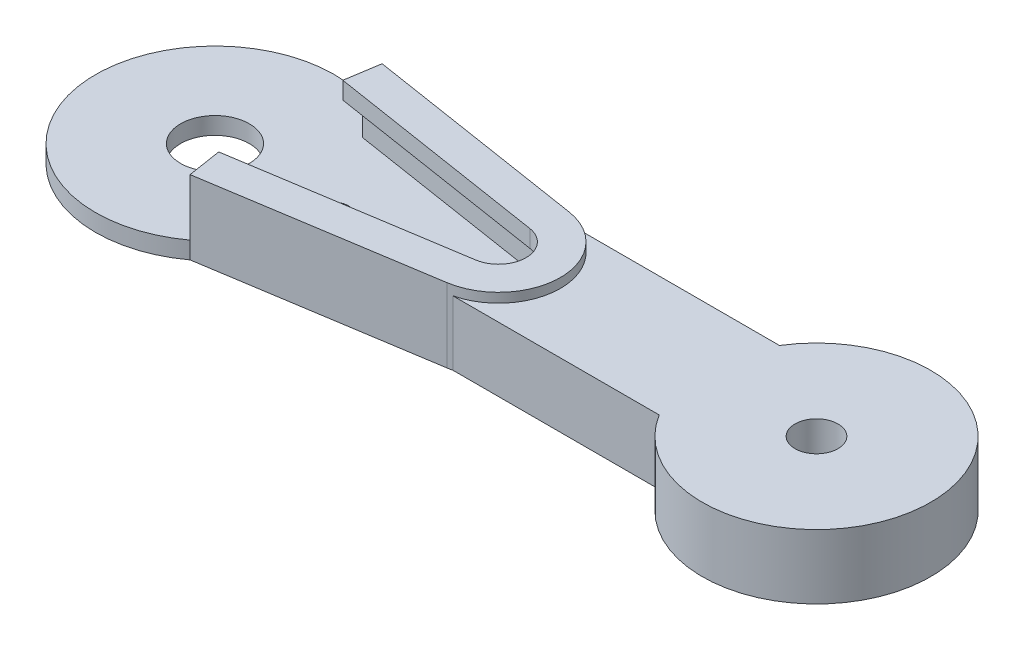
from build123d import *
from build123d.topology import SkipClean

# Parameters (mm, degrees)
SKETCH2_R               = 6
SKETCH2_R_2             = 1.5
BOSS_EXTRUDE1_DEPTH     = 1.15
SKETCH3_R               = 4.4
BOSS_EXTRUDE2_DEPTH     = 3.2
SKETCH4_R               = 0.75
BOSS_EXTRUDE3_DEPTH     = 1.15
CIRPATTERN1_COUNT       = 2
BOSS_EXTRUDE5_DEPTH     = 2.3
SKETCH7_R               = 2
BOSS_EXTRUDE6_DEPTH     = 1
CUT_EXTRUDE2_DEPTH      = 23.239726126
CUT_EXTRUDE4_DEPTH      = 2.3
SKETCH13_R              = 4.4
CUT_EXTRUDE5_DEPTH      = 3.3
BOSS_EXTRUDE8_DEPTH     = 1
SKETCH14_R              = 1.25
BOSS_EXTRUDE9_DEPTH     = 3.9
CUT_EXTRUDE6_DEPTH      = 10
CUT_EXTRUDE8_DEPTH      = 43.406107086
CUT_EXTRUDE8_DEPTH_BACK = 0.15


with BuildPart() as part:
    # Sketch2 → Boss-Extrude1 (new, symmetric)
    with BuildSketch(Plane(origin=(0, 0, 0), x_dir=(1, 0, 0), z_dir=(0, 1, 0))):
        with Locations(Location((0, 0, 0), (0, 0, 270))):
            Circle(SKETCH2_R)
        with Locations(Location((0, 0, 0), (0, 0, 270))):
            Circle(SKETCH2_R_2, mode=Mode.SUBTRACT)
    extrude(amount=BOSS_EXTRUDE1_DEPTH, both=True)

    # Sketch3 → Boss-Extrude2 (add)
    with BuildSketch(Plane(origin=(0, 1.15, 0), x_dir=(1, 0, 0), z_dir=(0, 1, 0))):
        with Locations(Location((0, 0, 0), (0, 0, 270))):
            Circle(SKETCH3_R)
        with BuildLine():
            Line((0.107421435, 2.898009771), (0.338399731, 2.678709694))
            Line((0.338399731, 2.678709694), (0.61665913, 2.83367809))
            ThreePointArc((0.61665913, 2.83367809), (0.721200673, 2.808891167), (0.824752316, 2.780248841))
            Line((0.824752316, 2.780248841), (0.993936292, 2.510396512))
            Line((0.993936292, 2.510396512), (1.301992734, 2.591295993))
            ThreePointArc((1.301992734, 2.591295993), (1.397085655, 2.541289372), (1.490260976, 2.48779465))
            Line((1.490260976, 2.48779465), (1.587020181, 2.184345885))
            Line((1.587020181, 2.184345885), (1.905517346, 2.186093238))
            ThreePointArc((1.905517346, 2.186093238), (1.985186607, 2.11400902), (2.062131058, 2.039023173))
            Line((2.062131058, 2.039023173), (2.080385755, 1.721044772))
            Line((2.080385755, 1.721044772), (2.389311295, 1.643530205))
            ThreePointArc((2.389311295, 1.643530205), (2.448550984, 1.553897705), (2.504429862, 1.46213237))
            Line((2.504429862, 1.46213237), (2.443033042, 1.149604087))
            Line((2.443033042, 1.149604087), (2.722976028, 0.997698125))
            ThreePointArc((2.722976028, 0.997698125), (2.758063897, 0.896149284), (2.789366126, 0.793370413))
            Line((2.789366126, 0.793370413), (2.652175577, 0.505929549))
            Line((2.652175577, 0.505929549), (2.885546163, 0.289177003))
            ThreePointArc((2.885546163, 0.289177003), (2.894277512, 0.182092507), (2.899036259, 0.074758075))
            Line((2.899036259, 0.074758075), (2.694672167, -0.169534403))
            Line((2.694672167, -0.169534403), (2.866806821, -0.437514174))
            ThreePointArc((2.866806821, -0.437514174), (2.848633027, -0.543405812), (2.826549281, -0.648551587))
            Line((2.826549281, -0.648551587), (2.567852594, -0.834345885))
            Line((2.567852594, -0.834345885), (2.667935462, -1.136714727))
            ThreePointArc((2.667935462, -1.136714727), (2.623998452, -1.234759946), (2.576459817, -1.331110368))
            Line((2.576459817, -1.331110368), (2.279685399, -1.446732346))
            Line((2.279685399, -1.446732346), (2.301427906, -1.764491312))
            ThreePointArc((2.301427906, -1.764491312), (2.234488404, -1.84852957), (2.164481907, -1.930030589))
            Line((2.164481907, -1.930030589), (1.848277186, -1.968215294))
            Line((1.848277186, -1.968215294), (1.790313171, -2.281398419))
            ThreePointArc((1.790313171, -2.281398419), (1.704577232, -2.346149284), (1.616501638, -2.40767989))
            Line((1.616501638, -2.40767989), (1.30073492, -2.366028036))
            Line((1.30073492, -2.366028036), (1.166706475, -2.654956874))
            ThreePointArc((1.166706475, -2.654956874), (1.067561203, -2.696351809), (0.966950626, -2.734045809))
            Line((0.966950626, -2.734045809), (0.671462695, -2.615174535))
            Line((0.671462695, -2.615174535), (0.469791321, -2.861694623))
            ThreePointArc((0.469791321, -2.861694623), (0.363466377, -2.877132634), (0.25664255, -2.888621575))
            Line((0.25664255, -2.888621575), (0, -2.7))
            Line((0, -2.7), (-0.25664255, -2.888621575))
            ThreePointArc((-0.25664255, -2.888621575), (-0.363466377, -2.877132634), (-0.469791321, -2.861694623))
            Line((-0.469791321, -2.861694623), (-0.671462695, -2.615174535))
            Line((-0.671462695, -2.615174535), (-0.966950626, -2.734045809))
            ThreePointArc((-0.966950626, -2.734045809), (-1.067561203, -2.696351809), (-1.166706475, -2.654956874))
            Line((-1.166706475, -2.654956874), (-1.30073492, -2.366028036))
            Line((-1.30073492, -2.366028036), (-1.616501638, -2.40767989))
            ThreePointArc((-1.616501638, -2.40767989), (-1.704577232, -2.346149284), (-1.790313171, -2.281398419))
            Line((-1.790313171, -2.281398419), (-1.848277186, -1.968215294))
            Line((-1.848277186, -1.968215294), (-2.164481907, -1.930030589))
            ThreePointArc((-2.164481907, -1.930030589), (-2.234488404, -1.84852957), (-2.301427906, -1.764491312))
            Line((-2.301427906, -1.764491312), (-2.279685399, -1.446732346))
            Line((-2.279685399, -1.446732346), (-2.576459817, -1.331110368))
            ThreePointArc((-2.576459817, -1.331110368), (-2.623998452, -1.234759946), (-2.667935462, -1.136714727))
            Line((-2.667935462, -1.136714727), (-2.567852594, -0.834345885))
            Line((-2.567852594, -0.834345885), (-2.826549281, -0.648551587))
            ThreePointArc((-2.826549281, -0.648551587), (-2.848633027, -0.543405812), (-2.866806821, -0.437514174))
            Line((-2.866806821, -0.437514174), (-2.694672167, -0.169534403))
            Line((-2.694672167, -0.169534403), (-2.899036259, 0.074758075))
            ThreePointArc((-2.899036259, 0.074758075), (-2.894277512, 0.182092507), (-2.885546163, 0.289177003))
            Line((-2.885546163, 0.289177003), (-2.652175577, 0.505929549))
            Line((-2.652175577, 0.505929549), (-2.789366126, 0.793370413))
            ThreePointArc((-2.789366126, 0.793370413), (-2.758063897, 0.896149284), (-2.722976028, 0.997698125))
            Line((-2.722976028, 0.997698125), (-2.443033042, 1.149604087))
            Line((-2.443033042, 1.149604087), (-2.504429862, 1.46213237))
            ThreePointArc((-2.504429862, 1.46213237), (-2.448550984, 1.553897705), (-2.389311295, 1.643530205))
            Line((-2.389311295, 1.643530205), (-2.080385755, 1.721044772))
            Line((-2.080385755, 1.721044772), (-2.062131058, 2.039023173))
            ThreePointArc((-2.062131058, 2.039023173), (-1.985186607, 2.11400902), (-1.905517346, 2.186093238))
            Line((-1.905517346, 2.186093238), (-1.587020181, 2.184345885))
            Line((-1.587020181, 2.184345885), (-1.490260976, 2.48779465))
            ThreePointArc((-1.490260976, 2.48779465), (-1.397085655, 2.541289372), (-1.301992734, 2.591295993))
            Line((-1.301992734, 2.591295993), (-0.993936292, 2.510396512))
            Line((-0.993936292, 2.510396512), (-0.824752316, 2.780248841))
            ThreePointArc((-0.824752316, 2.780248841), (-0.721200673, 2.808891167), (-0.61665913, 2.83367809))
            Line((-0.61665913, 2.83367809), (-0.338399731, 2.678709694))
            Line((-0.338399731, 2.678709694), (-0.107421435, 2.898009771))
            ThreePointArc((-0.107421435, 2.898009771), (0, 2.9), (0.107421435, 2.898009771))
        make_face(mode=Mode.SUBTRACT)
    extrude(amount=BOSS_EXTRUDE2_DEPTH)

    # Sketch4 → Boss-Extrude3 (add, symmetric)
    with BuildSketch(Plane(origin=(0, 0, 0), x_dir=(1, 0, 0), z_dir=(0, 1, 0))):
        with BuildLine():
            Line((3.968626967, 4.5), (16.888114198, 2.469689731))
            ThreePointArc((16.888114198, 2.469689731), (19, 0), (16.888114198, -2.469689731))
            Line((16.888114198, -2.469689731), (3.968626967, -4.5))
            ThreePointArc((3.968626967, -4.5), (6, 0), (3.968626967, 4.5))
        make_face()
        with Locations(Location((16, 0, 0), (0, 0, 270))):
            Circle(SKETCH4_R, mode=Mode.SUBTRACT)
        with Locations(Location((13, 0, 0), (0, 0, 270))):
            Circle(SKETCH4_R, mode=Mode.SUBTRACT)
        with Locations(Location((10, 0, 0), (0, 0, 270))):
            Circle(SKETCH4_R, mode=Mode.SUBTRACT)
        with Locations(Location((7, 0, 0), (0, 0, 270))):
            Circle(SKETCH4_R, mode=Mode.SUBTRACT)
    boss_extrude3 = extrude(amount=BOSS_EXTRUDE3_DEPTH, both=True)

    # CirPattern1: Boss-Extrude3 ×2 about axis
    cirpattern1_axis = Axis((0, 0, 0), (0, 1, 0))
    for i in range(1, CIRPATTERN1_COUNT):
        add(boss_extrude3.rotate(cirpattern1_axis, i * 360 / CIRPATTERN1_COUNT))



with BuildPart() as body_2:
    # Sketch6 → Boss-Extrude5 (new body)
    with BuildSketch(Plane.XZ.offset(1.15)):
        with BuildLine():
            Line((17.058884445, -3.556353213), (4.139397214, -5.586663482))
            Line((4.139397214, -5.586663482), (3.984151535, -4.598787589))
            Line((3.984151535, -4.598787589), (16.903638766, -2.568477321))
            ThreePointArc((16.903638766, -2.568477321), (19.1, 0), (16.903638766, 2.568477321))
            Line((16.903638766, 2.568477321), (3.984151535, 4.598787589))
            Line((3.984151535, 4.598787589), (4.139397214, 5.586663482))
            Line((4.139397214, 5.586663482), (17.058884445, 3.556353213))
            ThreePointArc((17.058884445, 3.556353213), (20.1, 0), (17.058884445, -3.556353213))
        make_face()
    extrude(amount=-BOSS_EXTRUDE5_DEPTH)


with BuildPart() as part_1:
    add(part.part)

    add(body_2.part)  # Boss-Extrude6 merges body 2
    # Sketch7 → Boss-Extrude6 (add)
    with BuildSketch(Plane.XZ.offset(1.15)):
        with BuildLine():
            Line((4.139397214, -5.586663482), (17.058884445, -3.556353213))
            ThreePointArc((17.058884445, -3.556353213), (20.1, 0), (17.058884445, 3.556353213))
            Line((17.058884445, 3.556353213), (4.139397214, 5.586663482))
            ThreePointArc((4.139397214, 5.586663482), (-6.953086951, 0), (4.139397214, -5.586663482))
        make_face()
        with Locations(Location((0, 0, 0), (0, 0, 270))):
            Circle(SKETCH7_R, mode=Mode.SUBTRACT)
    extrude(amount=BOSS_EXTRUDE6_DEPTH)

    # Sketch10 → Cut-Extrude2 (cut, through all)
    with SkipClean():  # the faces are left unmerged after this step: merging them gives an invalid solid
        with BuildSketch(Plane.XZ.offset(2.15)):
            with BuildLine():
                ThreePointArc((10.75, 0), (10, 0.75), (9.25, 0))
                Line((9.25, 0), (10.75, 0))
            make_face()
            with BuildLine():
                Line((10.75, 0), (9.25, 0))
                ThreePointArc((9.25, 0), (10, -0.75), (10.75, 0))
            make_face()
            with BuildLine():
                ThreePointArc((13.75, 0), (13, 0.75), (12.25, 0))
                Line((12.25, 0), (13.75, 0))
            make_face()
            with BuildLine():
                Line((13.75, 0), (12.25, 0))
                ThreePointArc((12.25, 0), (13, -0.75), (13.75, 0))
            make_face()
            with BuildLine():
                ThreePointArc((16.75, 0), (16, 0.75), (15.25, 0))
                Line((15.25, 0), (16.75, 0))
            make_face()
            with BuildLine():
                Line((16.75, 0), (15.25, 0))
                ThreePointArc((15.25, 0), (16, -0.75), (16.75, 0))
            make_face()
            with BuildLine():
                ThreePointArc((7.75, 0), (7, 0.75), (6.25, 0))
                Line((6.25, 0), (7.75, 0))
            make_face()
            with BuildLine():
                Line((7.75, 0), (6.25, 0))
                ThreePointArc((6.25, 0), (7, -0.75), (7.75, 0))
            make_face()
        extrude(amount=-CUT_EXTRUDE2_DEPTH, mode=Mode.SUBTRACT)

    # Sketch12 → Cut-Extrude4 (cut)
    with BuildSketch(Plane(origin=(0, 1.15, 0), x_dir=(1, 0, 0), z_dir=(0, 1, 0))):
        with BuildLine():
            Line((-3.968626967, 4.5), (-16.888114198, 2.469689731))
            ThreePointArc((-16.888114198, 2.469689731), (-19, 0), (-16.888114198, -2.469689731))
            Line((-16.888114198, -2.469689731), (-3.968626967, -4.5))
            ThreePointArc((-3.968626967, -4.5), (0, -6), (3.968626967, -4.5))
            Line((3.968626967, -4.5), (16.888114198, -2.469689731))
            ThreePointArc((16.888114198, -2.469689731), (19, 0), (16.888114198, 2.469689731))
            Line((16.888114198, 2.469689731), (3.968626967, 4.5))
            ThreePointArc((3.968626967, 4.5), (0, 6), (-3.968626967, 4.5))
        make_face()
    extrude(amount=-CUT_EXTRUDE4_DEPTH, mode=Mode.SUBTRACT)


with BuildPart() as cut_extrude4_piece_1:
    # of the separate pieces the step leaves, piece 1, a body of its own (cut_extrude4_pieces)
    add(part_1.part.solids().sort_by_distance((4.139397214, -1.15, -5.586663482))[0])

    # Sketch9 → Boss-Extrude8 (add)
    with BuildSketch(Plane(origin=(0, 1.15, 0), x_dir=(1, 0, 0), z_dir=(0, 1, 0))):
        with BuildLine():
            ThreePointArc((17.058884445, -3.556353213), (20.1, 0), (17.058884445, 3.556353213))
            Line((17.058884445, 3.556353213), (4.139397214, 5.586663482))
            Line((4.139397214, 5.586663482), (3.984151535, 4.598787589))
            Line((3.984151535, 4.598787589), (16.903638766, 2.568477321))
            ThreePointArc((16.903638766, 2.568477321), (19.1, 0), (16.903638766, -2.568477321))
            Line((16.903638766, -2.568477321), (3.984151535, -4.598787589))
            Line((3.984151535, -4.598787589), (4.139397214, -5.586663482))
            Line((4.139397214, -5.586663482), (17.058884445, -3.556353213))
        make_face()
        with BuildLine():
            ThreePointArc((16.748393087, -1.580601428), (18.1, 0), (16.748393087, 1.580601428))
            Line((16.748393087, 1.580601428), (3.828905855, 3.610911697))
            Line((3.828905855, 3.610911697), (3.984151535, 4.598787589))
            Line((3.984151535, 4.598787589), (16.903638766, 2.568477321))
            ThreePointArc((16.903638766, 2.568477321), (19.1, 0), (16.903638766, -2.568477321))
            Line((16.903638766, -2.568477321), (3.984151535, -4.598787589))
            Line((3.984151535, -4.598787589), (3.828905855, -3.610911697))
            Line((3.828905855, -3.610911697), (16.748393087, -1.580601428))
        make_face()
    extrude(amount=BOSS_EXTRUDE8_DEPTH)

    # Sketch14 → Boss-Extrude9 (add)
    # profile 1 of 5: a face of its own
    with BuildSketch(Plane.XZ.offset(2.15)):
        with BuildLine():
            Line((28, 0), (20.1, 0))
            ThreePointArc((20.1, 0), (19.327844932, -2.227844932), (17.342614977, -3.5))
            Line((17.342614977, -3.5), (28.937822174, -3.5))
            ThreePointArc((28.937822174, -3.5), (28.238519216, -1.811733316), (28, 0))
        make_face()
    # profile 2 of 5: a face of its own
    with BuildSketch(Plane.XZ.offset(2.15)):
        with BuildLine():
            ThreePointArc((17.342614977, 3.5), (19.327844932, 2.227844932), (20.1, 0))
            Line((20.1, 0), (28, 0))
            ThreePointArc((28, 0), (28.238519216, 1.811733316), (28.937822174, 3.5))
            Line((28.937822174, 3.5), (17.342614977, 3.5))
        make_face()
    # profile 3 of 5: a face of its own
    with BuildSketch(Plane.XZ.offset(2.15)):
        with BuildLine():
            Line((30.836953373, 3.5), (30.836953373, 0))
            Line((30.836953373, 0), (30.836953373, -3.5))
            Line((30.836953373, -3.5), (28.937822174, -3.5))
            ThreePointArc((28.937822174, -3.5), (36.811733316, -6.761480784), (42, 0))
            ThreePointArc((42, 0), (36.811733316, 6.761480784), (28.937822174, 3.5))
            Line((28.937822174, 3.5), (30.836953373, 3.5))
        make_face()
        with Locations(Location((35, 0, 0), (0, 0, 270))):
            Circle(SKETCH14_R, mode=Mode.SUBTRACT)
    # profile 4 of 5: a face of its own
    with BuildSketch(Plane.XZ.offset(2.15)):
        with BuildLine():
            Line((30.836953373, 0), (28, 0))
            ThreePointArc((28, 0), (28.238519216, -1.811733316), (28.937822174, -3.5))
            Line((28.937822174, -3.5), (30.836953373, -3.5))
            Line((30.836953373, -3.5), (30.836953373, 0))
        make_face()
    # profile 5 of 5: a face of its own
    with BuildSketch(Plane.XZ.offset(2.15)):
        with BuildLine():
            ThreePointArc((28.937822174, 3.5), (28.238519216, 1.811733316), (28, 0))
            Line((28, 0), (30.836953373, 0))
            Line((30.836953373, 0), (30.836953373, 3.5))
            Line((30.836953373, 3.5), (28.937822174, 3.5))
        make_face()
    extrude(amount=-BOSS_EXTRUDE9_DEPTH)

    # Sketch15 → Cut-Extrude6 (cut)
    with BuildSketch(Plane.XZ.offset(2.15)):
        with BuildLine():
            ThreePointArc((42, 0), (36.811733316, 6.761480784), (28.937822174, 3.5))
            Line((28.937822174, 3.5), (29.345576953, 3.5))
            ThreePointArc((29.345576953, 3.5), (36.819421163, 6.396265053), (41.65, 0))
            ThreePointArc((41.65, 0), (36.819421163, -6.396265053), (29.345576953, -3.5))
            Line((29.345576953, -3.5), (28.937822174, -3.5))
            ThreePointArc((28.937822174, -3.5), (36.811733316, -6.761480784), (42, 0))
        make_face()
    extrude(amount=-CUT_EXTRUDE6_DEPTH, mode=Mode.SUBTRACT)

    # Sketch17 → Cut-Extrude8 (cut, two sides: drawn at the far end of the back side and taken through both)
    with BuildSketch(Plane(origin=(0, 1.75, 0), x_dir=(1, 0, 0), z_dir=(0, 1, 0)).offset(-CUT_EXTRUDE8_DEPTH_BACK)):
        with BuildLine():
            Line((17.342614977, -3.5), (29.345576953, -3.5))
            ThreePointArc((29.345576953, -3.5), (41.65, 0), (29.345576953, 3.5))
            Line((29.345576953, 3.5), (17.342614977, 3.5))
            ThreePointArc((17.342614977, 3.5), (20.1, 0), (17.342614977, -3.5))
        make_face()
    extrude(amount=CUT_EXTRUDE8_DEPTH + CUT_EXTRUDE8_DEPTH_BACK, mode=Mode.SUBTRACT)


with BuildPart() as cut_extrude4_piece_2:
    # of the separate pieces the step leaves, piece 2, a body of its own (cut_extrude4_pieces)
    add(part_1.part.solids().sort_by_distance((0, 1.15, 4.4))[0])

    # Sketch13 → Cut-Extrude5 (cut)
    with BuildSketch(Plane(origin=(0, 4.35, 0), x_dir=(1, 0, 0), z_dir=(0, 1, 0))):
        Circle(SKETCH13_R)
    extrude(amount=-CUT_EXTRUDE5_DEPTH, mode=Mode.SUBTRACT)


solid = cut_extrude4_piece_1.part
